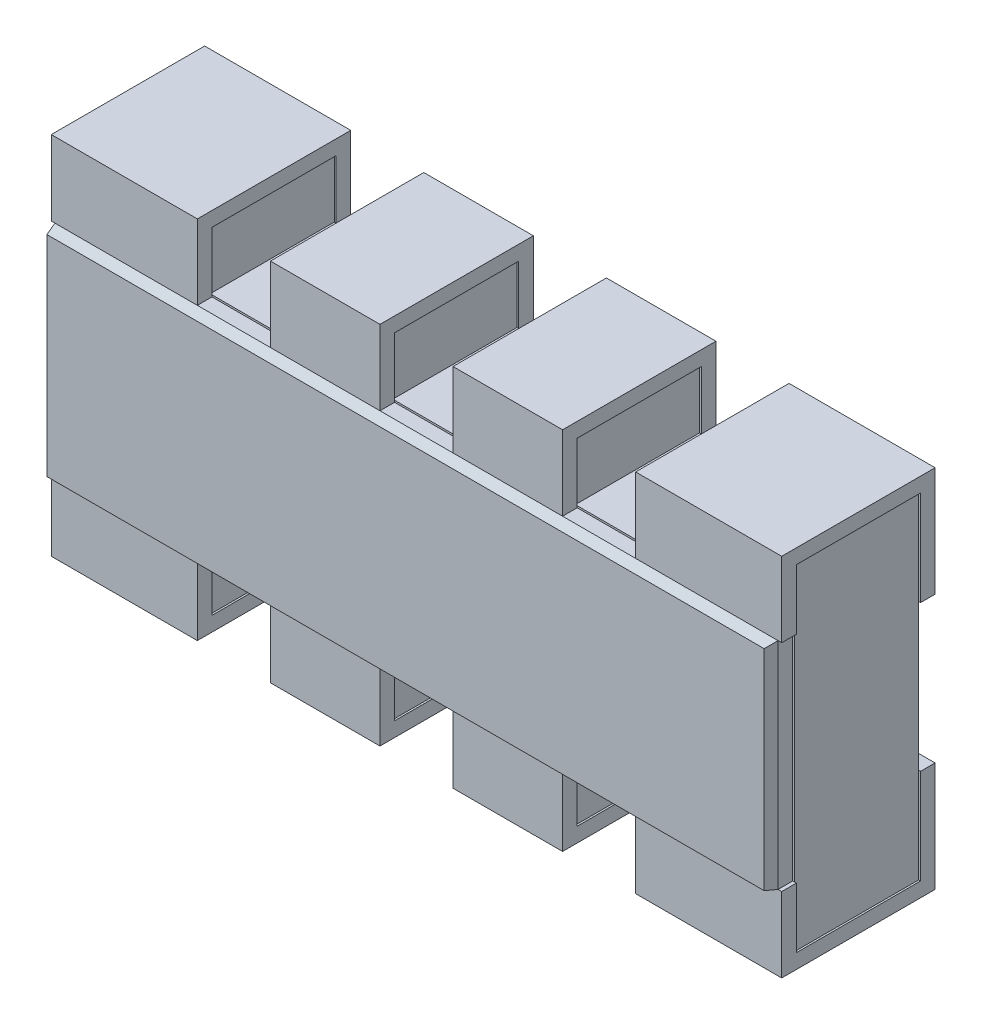
from build123d import *

# Parameters (mm, degrees)
EXTRUDE_START               = 0.04
EXTRUDE_1_DEPTH             = 0.34
EXTRUDE_START_2             = 0.42
SKETCH_2_W                  = 1.98
SKETCH_2_H                  = 0.59
EXTRUDE_1_2_DEPTH           = 0.03
EXTRUDE_1_2_TAPER           = 15
EXTRUDE_1_2_OTHER_WAY_DEPTH = 0.04
EXTRUDE_START_3             = -0.4
EXTRUDE_3_DEPTH             = 0.3
EXTRUDE_START_4             = -1
EXTRUDE_4_DEPTH             = 0.4
EXTRUDE_START_5             = 1
EXTRUDE_5_DEPTH             = 0.4
PATTERN_LINEAR_1_COUNT      = 2
PATTERN_LINEAR_1_PITCH      = 0.5


with BuildPart() as part:
    # Эскиз1 → Extrude 1 (new body)
    with BuildSketch(Plane.XY.offset(EXTRUDE_START)):
        Polygon((-0.605, 0.49), (-0.605, 0.3), (-0.395, 0.3), (-0.395, 0.49), (-0.105, 0.49), (-0.105, 0.3), (0.105, 0.3), (0.105, 0.49), (0.395, 0.49), (0.395, 0.3), (0.605, 0.3), (0.605, 0.49), (0.995, 0.49), (0.995, -0.49), (0.605, -0.49), (0.605, -0.3), (0.395, -0.3), (0.395, -0.49), (0.105, -0.49), (0.105, -0.3), (-0.105, -0.3), (-0.105, -0.49), (-0.395, -0.49), (-0.395, -0.3), (-0.605, -0.3), (-0.605, -0.49), (-0.995, -0.49), (-0.995, 0.49), align=None)
    extrude(amount=EXTRUDE_1_DEPTH)

    # Эскиз2 → Extrude 1 2 (add)
    with BuildSketch(Plane.XY.offset(EXTRUDE_START_2)):
        Rectangle(SKETCH_2_W, SKETCH_2_H)
    extrude(amount=EXTRUDE_1_2_DEPTH, taper=EXTRUDE_1_2_TAPER)

    # Эскиз2 → Extrude 1 2 other way (add)
    with BuildSketch(Plane.XY.offset(EXTRUDE_START_2)):
        Rectangle(SKETCH_2_W, SKETCH_2_H)
    extrude(amount=-EXTRUDE_1_2_OTHER_WAY_DEPTH)

    # Эскиз3 → Бобышка-Вытянуть3 (add)
    with BuildSketch(Plane(origin=(0, 0, 0), x_dir=(0, 0, -1), z_dir=(1, 0, 0)).offset(EXTRUDE_START_3)):
        Polygon((-0.42, 0.295), (-0.38, 0.295), (-0.38, 0.46), (-0.04, 0.46), (-0.04, 0.2), (0, 0.2), (0, 0.5), (-0.42, 0.5), align=None)
        Polygon((-0.04, -0.2), (0, -0.2), (0, -0.5), (-0.42, -0.5), (-0.42, -0.295), (-0.38, -0.295), (-0.38, -0.46), (-0.04, -0.46), align=None)
    extrude_3 = extrude(amount=EXTRUDE_3_DEPTH)

    # Эскиз3<2> → Бобышка-Вытянуть4 (add)
    with BuildSketch(Plane(origin=(0, 0, 0), x_dir=(0, 0, -1), z_dir=(1, 0, 0)).offset(EXTRUDE_START_4)):
        Polygon((-0.42, 0.295), (-0.38, 0.295), (-0.38, 0.46), (-0.04, 0.46), (-0.04, 0.2), (0, 0.2), (0, 0.5), (-0.42, 0.5), align=None)
        Polygon((-0.04, -0.2), (0, -0.2), (0, -0.5), (-0.42, -0.5), (-0.42, -0.295), (-0.38, -0.295), (-0.38, -0.46), (-0.04, -0.46), align=None)
    extrude(amount=EXTRUDE_4_DEPTH)

    # Эскиз3<3> → Бобышка-Вытянуть5 (add)
    with BuildSketch(Plane(origin=(0, 0, 0), x_dir=(0, 0, -1), z_dir=(1, 0, 0)).offset(EXTRUDE_START_5)):
        Polygon((-0.42, 0.295), (-0.38, 0.295), (-0.38, 0.46), (-0.04, 0.46), (-0.04, 0.2), (0, 0.2), (0, 0.5), (-0.42, 0.5), align=None)
        Polygon((-0.04, -0.2), (0, -0.2), (0, -0.5), (-0.42, -0.5), (-0.42, -0.295), (-0.38, -0.295), (-0.38, -0.46), (-0.04, -0.46), align=None)
    extrude(amount=-EXTRUDE_5_DEPTH)

    # Линейный массив1: Бобышка-Вытянуть3 ×2
    with Locations(*[(i * PATTERN_LINEAR_1_PITCH, 0, 0) for i in range(1, PATTERN_LINEAR_1_COUNT)]):
        add(extrude_3)


solid = part.part
